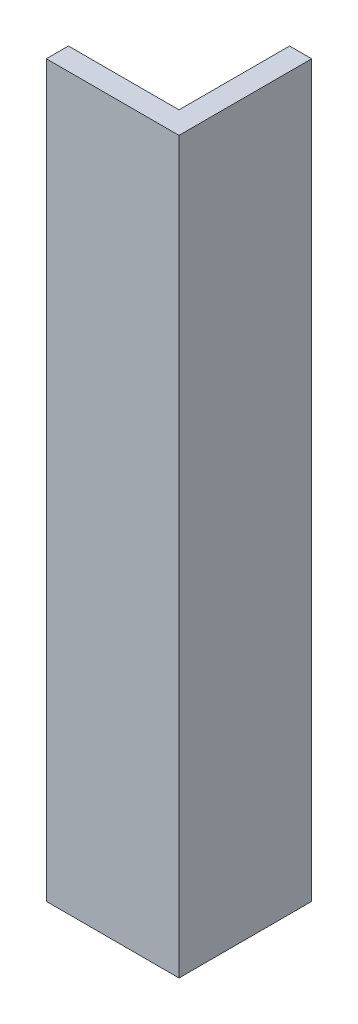
from build123d import *

# Parameters (mm, degrees)
BOSS_EXTRUDE1_DEPTH = 83.82


with BuildPart() as part:
    # Sketch1 → Boss-Extrude1 (new body)
    with BuildSketch(Plane(origin=(0, 0, 0), x_dir=(1, 0, 0), z_dir=(0, 1, 0))):
        Polygon((0, 2.54), (0, 0), (12.96366782, 0), (15.24, 0), (15.24, 2.54), (15.24, 15.24), (12.7, 15.24), (12.7, 2.54), align=None)
    extrude(amount=BOSS_EXTRUDE1_DEPTH)


solid = part.part
